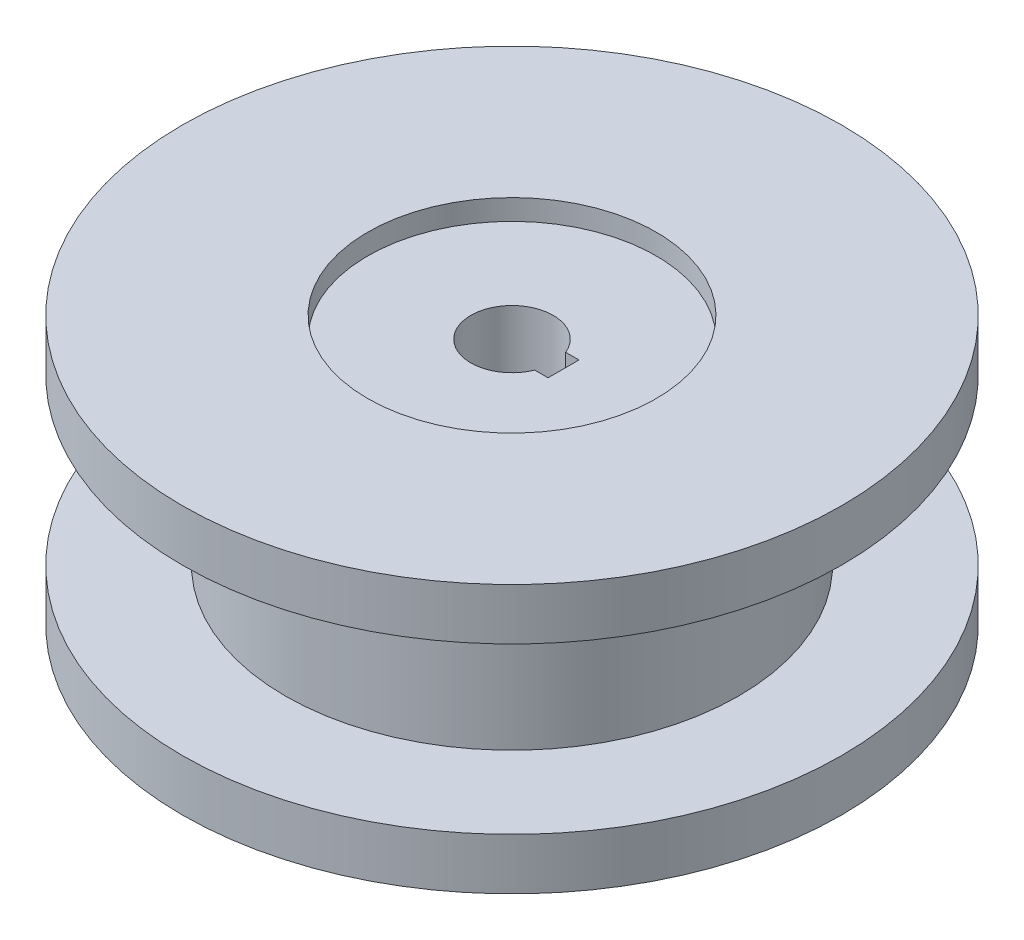
from build123d import *

# Parameters (mm, degrees)
SKETCH2_R          = 70
CUT_EXTRUDE1_DEPTH = 10
SKETCH3_R          = 20
CUT_EXTRUDE2_DEPTH = 121
SKETCH4_W          = 19.454924149
SKETCH4_H          = 15
CUT_EXTRUDE3_DEPTH = 121


with BuildPart() as part:
    # Sketch1 → Revolve1 (revolve)
    with BuildSketch(Plane.XY):
        Polygon((0, 65), (160, 65), (160, 40), (110, 40), (110, -40), (160, -40), (160, -65), (0, -65), align=None)
    revolve(axis=Axis((0, 93.810810811, 0), (0, -1, 0)))

    # Sketch2 → Cut-Extrude1 (cut)
    with BuildSketch(Plane(origin=(0, 65, 0), x_dir=(1, 0, 0), z_dir=(0, 1, 0))):
        Circle(SKETCH2_R)
    cut_extrude1 = extrude(amount=-CUT_EXTRUDE1_DEPTH, mode=Mode.SUBTRACT)

    # Mirror1: Cut-Extrude1 across plane
    add(cut_extrude1.mirror(Plane.ZX), mode=Mode.SUBTRACT)

    # Sketch3 → Cut-Extrude2 (cut, through all)
    with BuildSketch(Plane(origin=(0, 55, 0), x_dir=(1, 0, 0), z_dir=(0, 1, 0))):
        Circle(SKETCH3_R)
    extrude(amount=-CUT_EXTRUDE2_DEPTH, mode=Mode.SUBTRACT)

    # Sketch4 → Cut-Extrude3 (cut, through all)
    with BuildSketch(Plane(origin=(0, 55, 0), x_dir=(1, 0, 0), z_dir=(0, 1, 0))):
        with Locations((15.272537926, 0)):
            Rectangle(SKETCH4_W, SKETCH4_H)
    extrude(amount=-CUT_EXTRUDE3_DEPTH, mode=Mode.SUBTRACT)


solid = part.part
